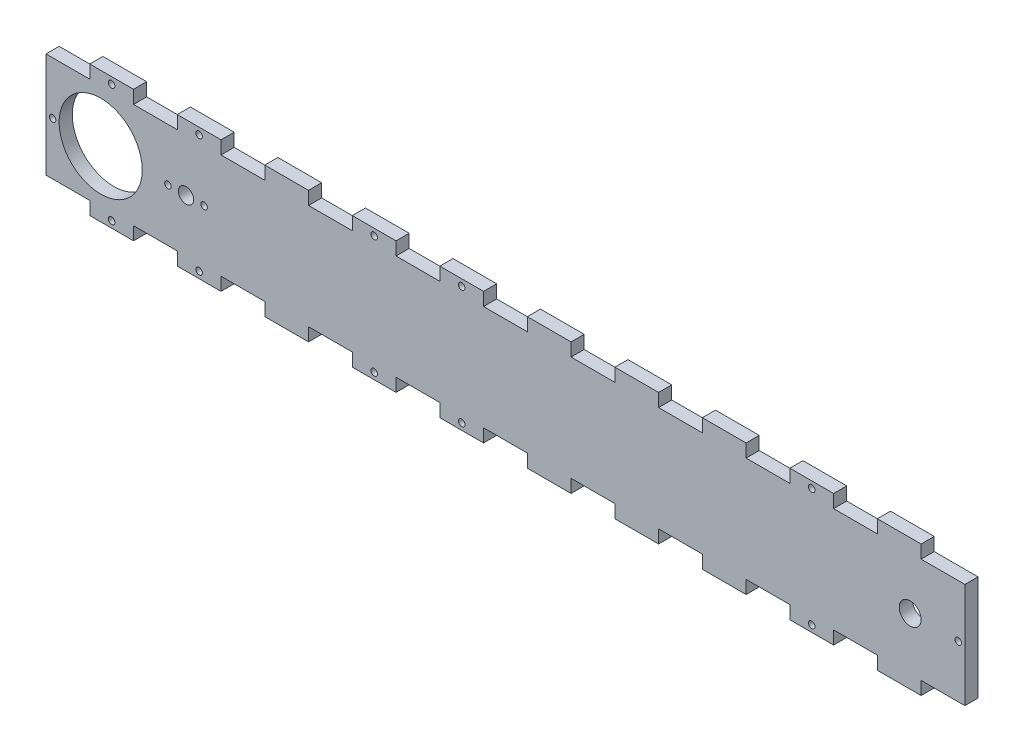
from build123d import *

# Parameters (mm, degrees)
BOSS_EXTRU_1_DEPTH      = 6
ESQUISSE3_R             = 19
ENL_V_MAT_EXTRU_1_DEPTH = 10
ESQUISSE4_W             = 20
ESQUISSE4_H             = 60
ENL_V_MAT_EXTRU_2_DEPTH = 10
ESQUISSE5_W             = 20
ESQUISSE5_H             = 48
BOSS_EXTRU_2_DEPTH      = 6
ESQUISSE6_R             = 1.5
ENL_V_MAT_EXTRU_3_DEPTH = 10
ESQUISSE7_R             = 1.5
ENL_V_MAT_EXTRU_4_DEPTH = 10
ESQUISSE8_R             = 1.5
ENL_V_MAT_EXTRU_5_DEPTH = 10
ESQUISSE9_R             = 3.5
ESQUISSE9_R_2           = 1.5
ENL_V_MAT_EXTRU_6_DEPTH = 10
ESQUISSE10_R            = 1.5
ENL_V_MAT_EXTRU_7_DEPTH = 10
ESQUISSE11_R            = 1.5
ENL_V_MAT_EXTRU_8_DEPTH = 10
ESQUISSE13_R            = 5
ENL_V_MAT_EXTRU_9_DEPTH = 10


with BuildPart() as part:
    # Esquisse2 → Boss.-Extru.1 (new body)
    with BuildSketch(Plane.XY):
        Polygon((-82.846139514, -43.409107348), (-62.846139514, -43.409107348), (-62.846139514, -37.409107348), (-42.846139514, -37.409107348), (-42.846139514, -43.409107348), (-22.846139514, -43.409107348), (-22.846139514, -37.409107348), (-2.846139514, -37.409107348), (-2.846139514, -43.409107348), (17.153860486, -43.409107348), (17.153860486, -37.409107348), (37.153860486, -37.409107348), (37.153860486, -43.409107348), (57.153860486, -43.409107348), (57.153860486, -37.409107348), (77.153860486, -37.409107348), (77.153860486, -43.409107348), (97.153860486, -43.409107348), (97.153860486, -37.409107348), (117.153860486, -37.409107348), (117.153860486, -43.409107348), (137.153860486, -43.409107348), (137.153860486, -37.409107348), (157.153860486, -37.409107348), (157.153860486, -43.409107348), (177.153860486, -43.409107348), (177.153860486, -37.409107348), (197.153860486, -37.409107348), (197.153860486, -43.409107348), (217.153860486, -43.409107348), (217.153860486, -37.409107348), (237.153860486, -37.409107348), (237.153860486, -43.409107348), (257.153860486, -43.409107348), (257.153860486, -37.409107348), (277.153860486, -37.409107348), (277.153860486, -43.409107348), (297.153860486, -43.409107348), (297.153860486, -37.409107348), (317.153860486, -37.409107348), (317.153860486, -43.409107348), (337.153860486, -43.409107348), (337.153860486, 16.590892652), (317.153860486, 16.590892652), (317.153860486, 10.590892652), (297.153860486, 10.590892652), (297.153860486, 16.590892652), (277.153860486, 16.590892652), (277.153860486, 10.590892652), (257.153860486, 10.590892652), (257.153860486, 16.590892652), (237.153860486, 16.590892652), (237.153860486, 10.590892652), (217.153860486, 10.590892652), (217.153860486, 16.590892652), (197.153860486, 16.590892652), (197.153860486, 10.590892652), (177.153860486, 10.590892652), (177.153860486, 16.590892652), (157.153860486, 16.590892652), (157.153860486, 10.590892652), (137.153860486, 10.590892652), (137.153860486, 16.590892652), (117.153860486, 16.590892652), (117.153860486, 10.590892652), (97.153860486, 10.590892652), (97.153860486, 16.590892652), (77.153860486, 16.590892652), (77.153860486, 10.590892652), (57.153860486, 10.590892652), (57.153860486, 16.590892652), (37.153860486, 16.590892652), (37.153860486, 10.590892652), (17.153860486, 10.590892652), (17.153860486, 16.590892652), (-2.846139514, 16.590892652), (-2.846139514, 10.590892652), (-22.846139514, 10.590892652), (-22.846139514, 16.590892652), (-42.846139514, 16.590892652), (-42.846139514, 10.590892652), (-62.846139514, 10.590892652), (-62.846139514, 16.590892652), (-82.846139514, 16.590892652), align=None)
    extrude(amount=BOSS_EXTRU_1_DEPTH)

    # Esquisse3 → Enlèv. mat.-Extru.1 (cut)
    with BuildSketch(Plane.XY.offset(6)):
        with Locations((-37.846139514, -13.409107348)):
            Circle(ESQUISSE3_R)
    extrude(amount=-ENL_V_MAT_EXTRU_1_DEPTH, mode=Mode.SUBTRACT)

    # Esquisse4 → Enlèv. mat.-Extru.2 (cut)
    with BuildSketch(Plane.XY.offset(6)):
        with Locations((-72.846139514, -13.409107348)):
            Rectangle(ESQUISSE4_W, ESQUISSE4_H)
    extrude(amount=-ENL_V_MAT_EXTRU_2_DEPTH, mode=Mode.SUBTRACT)

    # Esquisse5 → Boss.-Extru.2 (add)
    with BuildSketch(Plane.XY.offset(6)):
        with Locations((347.153860486, -13.409107348)):
            Rectangle(ESQUISSE5_W, ESQUISSE5_H)
    extrude(amount=-BOSS_EXTRU_2_DEPTH)

    # Esquisse6 → Enlèv. mat.-Extru.3 (cut)
    with BuildSketch(Plane.XY.offset(6)):
        with Locations((127.153860486, -40.409107348)):
            Circle(ESQUISSE6_R)
        with Locations((287.153860486, -40.409107348)):
            Circle(ESQUISSE6_R)
        with Locations((7.153860486, -40.409107348)):
            Circle(ESQUISSE6_R)
        with Locations((7.153860486, 13.590892652)):
            Circle(ESQUISSE6_R)
        with Locations((127.153860486, 13.590892652)):
            Circle(ESQUISSE6_R)
        with Locations((287.153860486, 13.590892652)):
            Circle(ESQUISSE6_R)
    extrude(amount=-ENL_V_MAT_EXTRU_3_DEPTH, mode=Mode.SUBTRACT)

    # Esquisse7 → Enlèv. mat.-Extru.4 (cut)
    with BuildSketch(Plane.XY.offset(6)):
        with Locations((-59.846139514, -13.409107348)):
            Circle(ESQUISSE7_R)
    extrude(amount=-ENL_V_MAT_EXTRU_4_DEPTH, mode=Mode.SUBTRACT)

    # Esquisse8 → Enlèv. mat.-Extru.5 (cut)
    with BuildSketch(Plane.XY.offset(6)):
        with Locations((354.153860486, -13.409107348)):
            Circle(ESQUISSE8_R)
    extrude(amount=-ENL_V_MAT_EXTRU_5_DEPTH, mode=Mode.SUBTRACT)

    # Esquisse9 → Enlèv. mat.-Extru.6 (cut)
    with BuildSketch(Plane.XY.offset(6)):
        with Locations((1.153860486, -13.409107348)):
            Circle(ESQUISSE9_R)
        with Locations((-7.096139514, -13.409107348)):
            Circle(ESQUISSE9_R_2)
        with Locations((9.403860486, -13.409107348)):
            Circle(ESQUISSE9_R_2)
    extrude(amount=-ENL_V_MAT_EXTRU_6_DEPTH, mode=Mode.SUBTRACT)

    # Esquisse10 → Enlèv. mat.-Extru.7 (cut)
    with BuildSketch(Plane.XY.offset(6)):
        with Locations((-32.846139514, 13.590892652)):
            Circle(ESQUISSE10_R)
        with Locations((-32.846139514, -40.409107348)):
            Circle(ESQUISSE10_R)
    extrude(amount=-ENL_V_MAT_EXTRU_7_DEPTH, mode=Mode.SUBTRACT)

    # Esquisse11 → Enlèv. mat.-Extru.8 (cut)
    with BuildSketch(Plane.XY.offset(6)):
        with Locations((87.153860486, 13.590892652)):
            Circle(ESQUISSE11_R)
        with Locations((87.153860486, -40.409107348)):
            Circle(ESQUISSE11_R)
    extrude(amount=-ENL_V_MAT_EXTRU_8_DEPTH, mode=Mode.SUBTRACT)

    # Esquisse13 → Enlèv. mat.-Extru.9 (cut)
    with BuildSketch(Plane.XY.offset(6)):
        with Locations((332.153860486, -13.409107348)):
            Circle(ESQUISSE13_R)
    extrude(amount=-ENL_V_MAT_EXTRU_9_DEPTH, mode=Mode.SUBTRACT)


solid = part.part
